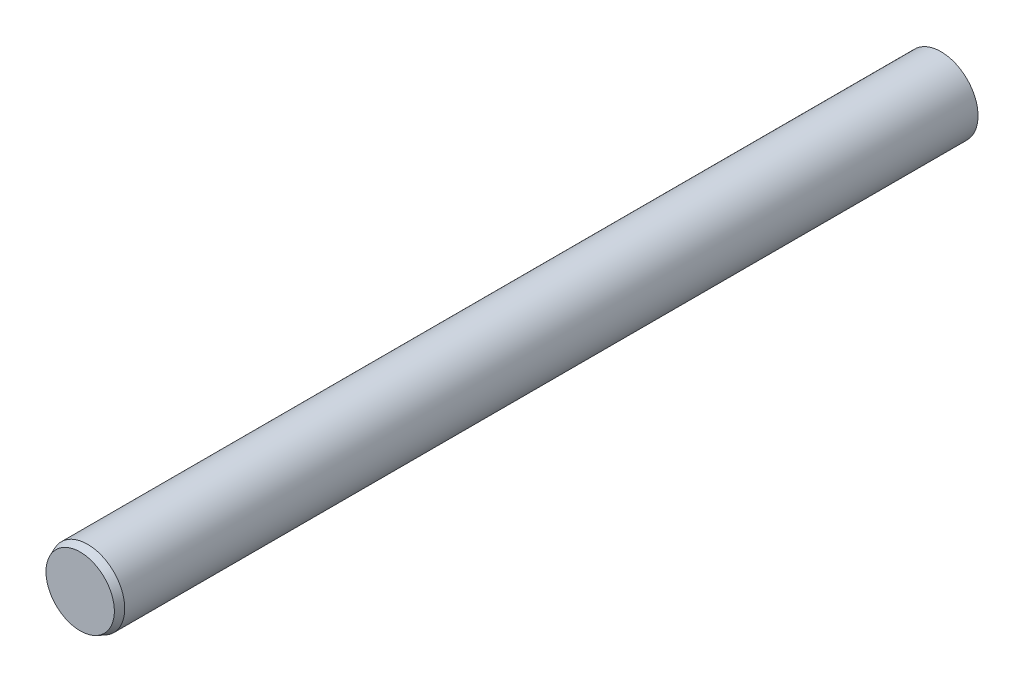
from build123d import *


with BuildPart() as part:
    # Sketch1 → Revolve1 (revolve)
    with BuildSketch(Plane.XZ):
        Polygon((2.3, 20.266), (0, 20.266), (0, -37.654), (2.5, -37.654), (2.5, 19.766), align=None)
    revolve(axis=Axis((0, 0, 20.266), (0, 0, -1)))


solid = part.part
